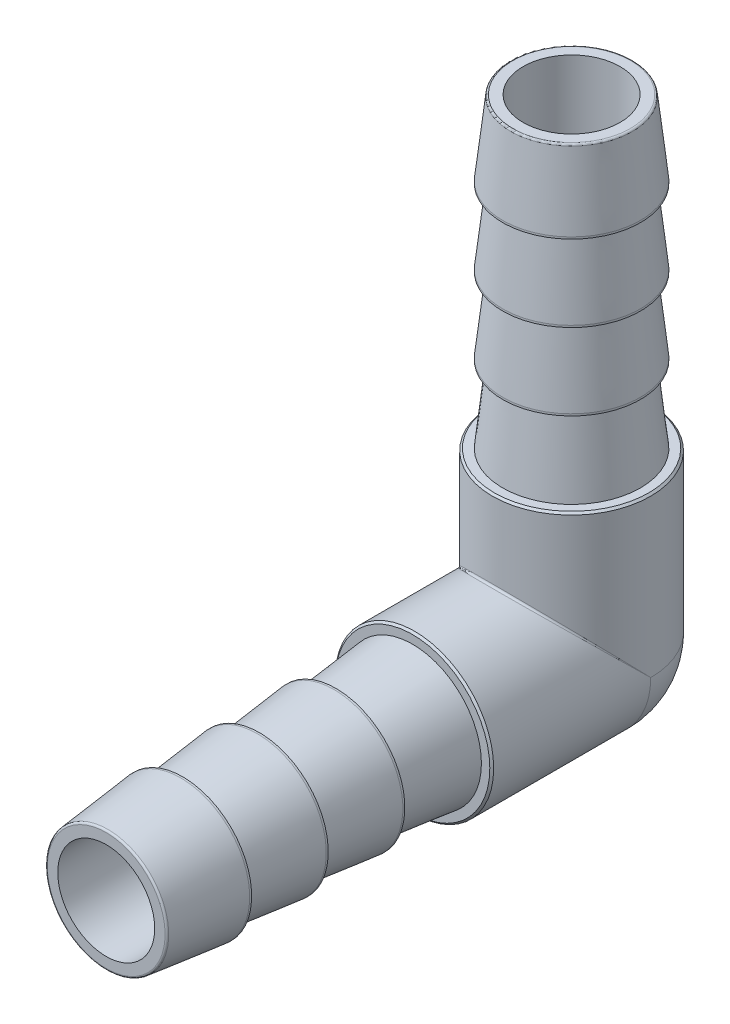
from build123d import *

# Parameters (mm, degrees)
LPATTERN1_COUNT              = 3
LPATTERN1_PITCH              = 5.0165
CHAMFER1_SIZE                = 0.127
CIRPATTERN1_COUNT            = 2
CIRPATTERN1_ANGLE            = 90
CHAMFER1_OF_CIRPATTERN1_SIZE = 0.127
CIRPATTERN2_COUNT            = 2
CIRPATTERN2_ANGLE            = 90
FILLET2_R                    = 0.127


with BuildPart() as part:
    # Sketch2 → Revolve1 (revolve)
    with BuildSketch(Plane(origin=(0, 0, 0), x_dir=(0, 0, -1), z_dir=(1, 0, 0)), mode=Mode.PRIVATE) as revolve1_sk:
        with BuildLine():
            Line((-30.48, 0), (-30.48, 5.184775))
            Line((-30.48, 5.184775), (0, 5.184775))
            ThreePointArc((0, 5.184775), (3.666189561, 3.666189561), (5.184775, 0))
            Line((5.184775, 0), (-30.48, 0))
        make_face()
    revolve1 = revolve(revolve1_sk.sketch.rotate(Axis((0, 0, 30.48), (0, 0, -1)), 90), axis=Axis((0, 0, 30.48), (0, 0, -1)))

    # Sketch3 → Cut-Revolve1 (revolve, cut)
    with BuildSketch(Plane(origin=(0, 0, 0), x_dir=(0, 0, -1), z_dir=(1, 0, 0)), mode=Mode.PRIVATE) as cut_revolve1_sk:
        Polygon((-30.48, 5.184775), (-30.48, 3.96875), (-15.4305, 3.96875), (-10.414, 4.5085), (-10.414, 5.184775), align=None)
    cut_revolve1 = revolve(cut_revolve1_sk.sketch.rotate(Axis((0, 0, 30.48), (0, 0, -1)), 90), axis=Axis((0, 0, 30.48), (0, 0, -1)), mode=Mode.SUBTRACT)

    # Sketch4 → Revolve2 (revolve)
    with BuildSketch(Plane(origin=(0, 0, 0), x_dir=(0, 0, -1), z_dir=(1, 0, 0))):
        Polygon((-25.4635, 4.5085), (-25.5905, 4.5085), (-30.48, 3.96875), (-25.4635, 3.96875), align=None)
    revolve2 = revolve(axis=Axis((0, 0, 10.414), (0, 0, 1)))

    # LPattern1: Revolve2 ×3
    with Locations(*[(0, 0, -i * LPATTERN1_PITCH) for i in range(1, LPATTERN1_COUNT)]):
        add(revolve2)

    # Chamfer1
    chamfer1_edges = [part.edges().sort_by_distance(p)[0] for p in [
        (-5.184775, 0, 10.414),
    ]]
    chamfer(chamfer1_edges, length=CHAMFER1_SIZE)

    # CirPattern1: Revolve1, Cut-Revolve1, Revolve2 ×2 about axis
    cirpattern1_axis = Axis((-6.6671825, 0, 0), (-1, 0, 0))
    add([revolve1.rotate(cirpattern1_axis, i * CIRPATTERN1_ANGLE / (CIRPATTERN1_COUNT - 1)) for i in range(1, CIRPATTERN1_COUNT)])
    add([cut_revolve1.rotate(cirpattern1_axis, i * CIRPATTERN1_ANGLE / (CIRPATTERN1_COUNT - 1)) for i in range(1, CIRPATTERN1_COUNT)], mode=Mode.SUBTRACT)
    add([revolve2.rotate(cirpattern1_axis, i * CIRPATTERN1_ANGLE / (CIRPATTERN1_COUNT - 1)) for i in range(1, CIRPATTERN1_COUNT)])

    # CirPattern1 copy 1 sketch → CirPattern1 copy 1 (revolve)
    with BuildSketch(Plane(origin=(0, -5.0165, 0), x_dir=(0, -1, 0), z_dir=(1, 0, 0))):
        Polygon((-25.4635, 4.5085), (-25.5905, 4.5085), (-30.48, 3.96875), (-25.4635, 3.96875), align=None)
    revolve(axis=Axis((0, 5.3975, 0), (0, 1, 0)))

    # CirPattern1 copy 2 sketch → CirPattern1 copy 2 (revolve)
    with BuildSketch(Plane(origin=(0, -10.033, 0), x_dir=(0, -1, 0), z_dir=(1, 0, 0))):
        Polygon((-25.4635, 4.5085), (-25.5905, 4.5085), (-30.48, 3.96875), (-25.4635, 3.96875), align=None)
    revolve(axis=Axis((0, 0.381, 0), (0, 1, 0)))

    # Chamfer1 of CirPattern1
    chamfer1_of_cirpattern1_edges = [part.edges().sort_by_distance(p)[0] for p in [
        (-5.184775, 10.414, 0),
    ]]
    chamfer(chamfer1_of_cirpattern1_edges, length=CHAMFER1_OF_CIRPATTERN1_SIZE)

    # Sketch5 → Cut-Revolve2 (revolve, cut)
    with BuildSketch(Plane(origin=(0, 0, 0), x_dir=(0, 0, -1), z_dir=(1, 0, 0)), mode=Mode.PRIVATE) as cut_revolve2_sk:
        with BuildLine():
            Line((-30.48, 3.175), (0, 3.175))
            ThreePointArc((0, 3.175), (2.24506403, 2.24506403), (3.175, 0))
            Line((3.175, 0), (-30.48, 0))
            Line((-30.48, 0), (-30.48, 3.175))
        make_face()
    cut_revolve2 = revolve(cut_revolve2_sk.sketch.rotate(Axis((0, 0, 30.48), (0, 0, -1)), 270), axis=Axis((0, 0, 30.48), (0, 0, -1)), mode=Mode.SUBTRACT)

    # CirPattern2: Cut-Revolve2 ×2 about axis
    cirpattern2_axis = Axis((-6.6671825, 0, 0), (-1, 0, 0))
    for i in range(1, CIRPATTERN2_COUNT):
        add(cut_revolve2.rotate(cirpattern2_axis, i * CIRPATTERN2_ANGLE / (CIRPATTERN2_COUNT - 1)), mode=Mode.SUBTRACT)

    # Fillet2
    fillet2_edges = [part.edges().sort_by_distance(p)[0] for p in [
        (0, -3.96875, 30.48),
        (5.714e-06, 5.184775, 5.184775),
        (0, 30.48, 3.96875),
    ]]
    fillet(fillet2_edges, radius=FILLET2_R)


solid = part.part
